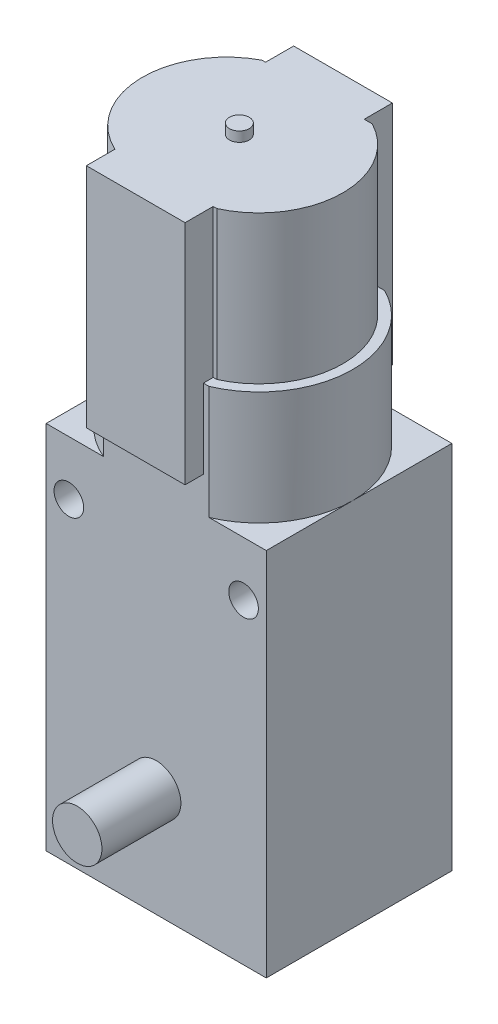
from build123d import *

# Parameters (mm, degrees)
SKETCH_1_W          = 22.3
SKETCH_1_H          = 18.8
EXTRUDE_1_DEPTH     = 37.5
EXTRUDE_2_DEPTH     = 11.5
EXTRUDE_3_DEPTH     = 15
SKETCH_6_R          = 1
EXTRUDE_5_DEPTH     = 1
SKETCH_7_W          = 5
SKETCH_7_H          = 3
EXTRUDE_6_DEPTH     = 5
CUT_EXTRUDE_1_DEPTH = 12.65
SKETCH_9_R          = 1
EXTRUDE_7_DEPTH     = 8
SKETCH_10_R         = 2.5
EXTRUDE_8_DEPTH     = 8
EXTRUDE_9_DEPTH     = 23
SKETCH_12_R         = 1.5
CUT_EXTRUDE_2_DEPTH = 27.8


with BuildPart() as part:
    # 草图1 → 凸台-拉伸1 (new body)
    with BuildSketch(Plane(origin=(0, 0, 0), x_dir=(1, 0, 0), z_dir=(0, 1, 0))):
        Rectangle(SKETCH_1_W, SKETCH_1_H)
    extrude(amount=EXTRUDE_1_DEPTH)

    # 草图2 → 凸台-拉伸2 (add)
    with BuildSketch(Plane(origin=(0, 37.5, 0), x_dir=(1, 0, 0), z_dir=(0, 1, 0))):
        with BuildLine():
            Line((-5.34468737, -9.4), (5.34468737, -9.4))
            ThreePointArc((5.34468737, -9.4), (9.566941985, -5.894406054), (11.15, -0.63983183))
            ThreePointArc((11.15, -0.63983183), (9.710419772, 4.391536027), (5.827413939, 7.9))
            Line((5.827413939, 7.9), (0, 7.9))
            Line((0, 7.9), (-5.827413939, 7.9))
            ThreePointArc((-5.827413939, 7.9), (-9.536938213, 4.659739509), (-11.12855374, -0.001442574))
            ThreePointArc((-11.12855374, -0.001442574), (-11.144636924, -0.320457147), (-11.15, -0.639831856))
            ThreePointArc((-11.15, -0.639831856), (-9.566941978, -5.894406065), (-5.34468737, -9.4))
        make_face()
    extrude(amount=EXTRUDE_2_DEPTH)

    # 草图3 → 凸台-拉伸3 (add)
    with BuildSketch(Plane(origin=(0, 49, 0), x_dir=(1, 0, 0), z_dir=(0, 1, 0))):
        with BuildLine():
            Line((-5.135942831, -8.4), (5.135942831, -8.4))
            ThreePointArc((5.135942831, -8.4), (10.146278436, -0.891512764), (5.588518865, 6.9))
            Line((5.588518865, 6.9), (-5.588518865, 6.9))
            ThreePointArc((-5.588518865, 6.9), (-10.146278436, -0.891512764), (-5.135942831, -8.4))
        make_face()
    extrude(amount=EXTRUDE_3_DEPTH)

    # 草图6 → 凸台-拉伸5 (add)
    with BuildSketch(Plane(origin=(0, 64, 0), x_dir=(1, 0, 0), z_dir=(0, 1, 0))):
        with Locations((-0.226288017, -0.75)):
            Circle(SKETCH_6_R)
    extrude(amount=EXTRUDE_5_DEPTH)

    # 草图7 → 凸台-拉伸6 (add)
    with BuildSketch(Plane.XZ):
        with Locations((0, 0.75)):
            Rectangle(SKETCH_7_W, SKETCH_7_H)
    extrude(amount=EXTRUDE_6_DEPTH)

    # 草图8 → 切除-拉伸1 (cut, through all)
    with BuildSketch(Plane.XY.offset(2.25)):
        with BuildLine():
            ThreePointArc((1.5, -2.5), (0.574025149, -1.114180701), (-1.060660172, -1.439339828))
            Line((-1.060660172, -1.439339828), (1.060660172, -3.560660172))
            ThreePointArc((1.060660172, -3.560660172), (1.385819299, -3.074025149), (1.5, -2.5))
        make_face()
        with BuildLine():
            Line((1.060660172, -3.560660172), (-1.060660172, -1.439339828))
            ThreePointArc((-1.060660172, -1.439339828), (-1.060660172, -3.560660172), (1.060660172, -3.560660172))
        make_face()
    extrude(amount=-CUT_EXTRUDE_1_DEPTH, mode=Mode.SUBTRACT)

    # 草图9 → 凸台-拉伸7 (add)
    with BuildSketch(Plane(origin=(0, 0, -9.4), x_dir=(-1, 0, 0), z_dir=(0, 0, -1))):
        with BuildLine():
            Line((2.6, 11), (0, 8.4))
            ThreePointArc((0, 8.4), (-1.838477631, 9.161522369), (-2.6, 11))
            Line((-2.6, 11), (0, 13.6))
            ThreePointArc((0, 13.6), (1.838477631, 12.838477631), (2.6, 11))
        make_face()
        with Locations((0, 11)):
            Circle(SKETCH_9_R, mode=Mode.SUBTRACT)
    extrude(amount=EXTRUDE_7_DEPTH)

    # 草图10 → 凸台-拉伸8 (add)
    with BuildSketch(Plane.XY.offset(9.4)):
        with Locations((0, 11)):
            Circle(SKETCH_10_R)
    extrude(amount=EXTRUDE_8_DEPTH)

    # 草图11 → 凸台-拉伸9 (add)
    with BuildSketch(Plane(origin=(0, 64, 0), x_dir=(1, 0, 0), z_dir=(0, 1, 0))):
        with BuildLine():
            Line((-5.226288017, -6.705208095), (-5.226288017, -11.25))
            Line((-5.226288017, -11.25), (4.773711983, -11.25))
            Line((4.773711983, -11.25), (4.773711983, -6.705208095))
            ThreePointArc((4.773711983, -6.705208095), (7.549604437, -0.75), (4.773711983, 5.205208095))
            Line((4.773711983, 5.205208095), (4.773711983, 9.75))
            Line((4.773711983, 9.75), (-0.226288017, 9.75))
            Line((-0.226288017, 9.75), (-5.226288017, 9.75))
            Line((-5.226288017, 9.75), (-5.226288017, 5.205208095))
            ThreePointArc((-5.226288017, 5.205208095), (-8.002180472, -0.75), (-5.226288017, -6.705208095))
        make_face()
    extrude(amount=-EXTRUDE_9_DEPTH)

    # 草图12 → 切除-拉伸2 (cut, through all)
    with BuildSketch(Plane(origin=(0, 0, -9.4), x_dir=(-1, 0, 0), z_dir=(0, 0, -1))):
        with Locations((-8.85, 32)):
            Circle(SKETCH_12_R)
        with Locations((8.85, 32)):
            Circle(SKETCH_12_R)
    extrude(amount=-CUT_EXTRUDE_2_DEPTH, mode=Mode.SUBTRACT)


solid = part.part
